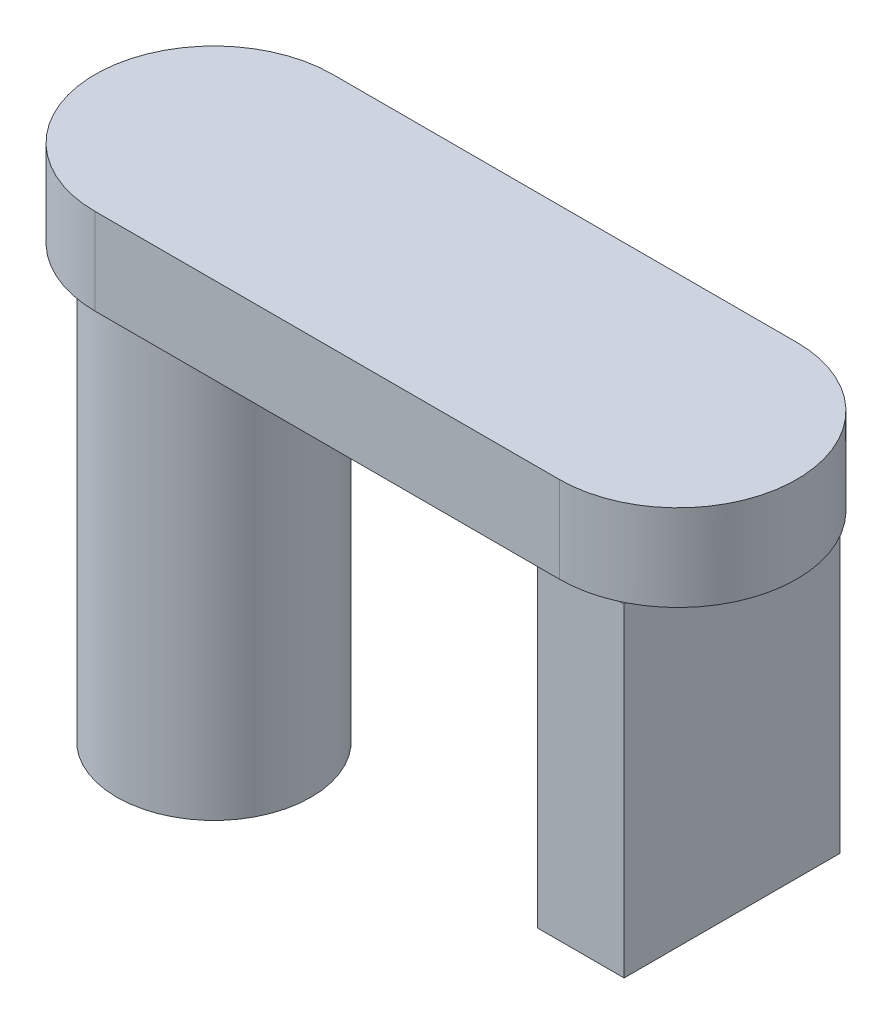
from build123d import *

# Parameters (mm, degrees)
SKETCH1_R             = 0.45
BOSS_EXTRUDE1_DEPTH   = 2
SKETCH1_W             = 0.4
SKETCH1_H             = 1
BOSS_EXTRUDE1_2_DEPTH = 2
BOSS_EXTRUDE2_DEPTH   = 0.4
SKETCH3_W             = 0.4
SKETCH3_H             = 1
CUT_EXTRUDE1_DEPTH    = 0.5


with BuildPart() as part:
    # Sketch1 → Boss-Extrude1 (new body)
    with BuildSketch(Plane(origin=(0, 0, 0), x_dir=(1, 0, 0), z_dir=(0, 1, 0))):
        Circle(SKETCH1_R)
    extrude(amount=BOSS_EXTRUDE1_DEPTH)



with BuildPart() as body_2:
    # Sketch1 → Boss-Extrude1 2 (new body)
    with BuildSketch(Plane(origin=(0, 0, 0), x_dir=(1, 0, 0), z_dir=(0, 1, 0))):
        with Locations((2.2, 0)):
            Rectangle(SKETCH1_W, SKETCH1_H)
    extrude(amount=BOSS_EXTRUDE1_2_DEPTH)


with BuildPart() as part_1:
    add(part.part)

    add(body_2.part)  # Boss-Extrude2 merges body 2
    # Sketch2 → Boss-Extrude2 (add)
    with BuildSketch(Plane(origin=(0, 2, 0), x_dir=(1, 0, 0), z_dir=(0, 1, 0))):
        with BuildLine():
            Line((0, 0.55), (2.15, 0.55))
            ThreePointArc((2.15, 0.55), (2.7, 0), (2.15, -0.55))
            Line((2.15, -0.55), (0, -0.55))
            ThreePointArc((0, -0.55), (-0.55, 0), (0, 0.55))
        make_face()
    extrude(amount=BOSS_EXTRUDE2_DEPTH)

    # Sketch3 → Cut-Extrude1 (cut)
    with BuildSketch(Plane.XZ):
        with Locations((2.2, 0)):
            Rectangle(SKETCH3_W, SKETCH3_H)
    extrude(amount=-CUT_EXTRUDE1_DEPTH, mode=Mode.SUBTRACT)


solid = part_1.part
